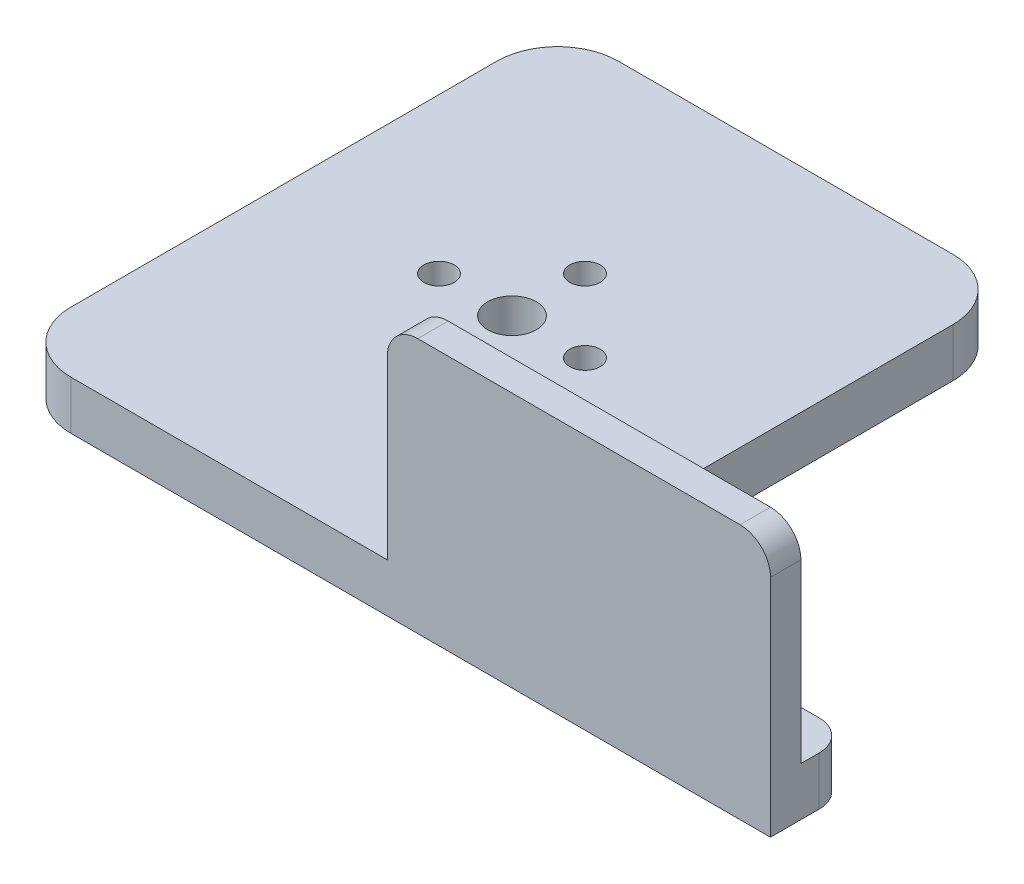
from build123d import *

# Parameters (mm, degrees)
SKETCH1_W           = 75
SKETCH1_H           = 90
SKETCH1_W_2         = 50
SKETCH1_H_2         = 13
BOSS_EXTRUDE1_DEPTH = 8
FILLET2_R           = 10
FILLET3_R           = 10
FILLET4_R           = 10
SKETCH7_W           = 5
SKETCH7_H           = 34
BOSS_EXTRUDE3_DEPTH = 63
FILLET5_R           = 5
FILLET6_R           = 5
FILLET7_R           = 5
SKETCH2_R           = 16
CUT_EXTRUDE1_DEPTH  = 1
CUT_EXTRUDE2_REACH  = 43
SKETCH8_R           = 2.5
SKETCH8_R_2         = 4


with BuildPart() as part:
    # Sketch1 → Boss-Extrude1 (new body)
    with BuildSketch(Plane(origin=(0, 0, 0), x_dir=(1, 0, 0), z_dir=(0, 1, 0))):
        with Locations((37.5, -45)):
            Rectangle(SKETCH1_W, SKETCH1_H)
        with Locations((100, -83.5)):
            Rectangle(SKETCH1_W_2, SKETCH1_H_2)
    extrude(amount=BOSS_EXTRUDE1_DEPTH)

    # Fillet2
    fillet2_edges = [part.edges().sort_by_distance(p)[0] for p in [
        (0, 4, 0),
    ]]
    fillet(fillet2_edges, radius=FILLET2_R)

    # Fillet3
    fillet3_edges = [part.edges().sort_by_distance(p)[0] for p in [
        (0, 4, 90),
    ]]
    fillet(fillet3_edges, radius=FILLET3_R)

    # Fillet4
    fillet4_edges = [part.edges().sort_by_distance(p)[0] for p in [
        (75, 4, 0),
    ]]
    fillet(fillet4_edges, radius=FILLET4_R)

    # Sketch7 → Boss-Extrude3 (add)
    with BuildSketch(Plane(origin=(125, 0, 0), x_dir=(0, 0, -1), z_dir=(1, 0, 0))):
        with Locations((-87.5, 25)):
            Rectangle(SKETCH7_W, SKETCH7_H)
    extrude(amount=-BOSS_EXTRUDE3_DEPTH)

    # Fillet5
    fillet5_edges = [part.edges().sort_by_distance(p)[0] for p in [
        (125, 42, 87.5),
    ]]
    fillet(fillet5_edges, radius=FILLET5_R)

    # Fillet6
    fillet6_edges = [part.edges().sort_by_distance(p)[0] for p in [
        (125, 4, 77),
    ]]
    fillet(fillet6_edges, radius=FILLET6_R)

    # Fillet7
    fillet7_edges = [part.edges().sort_by_distance(p)[0] for p in [
        (62, 42, 87.5),
    ]]
    fillet(fillet7_edges, radius=FILLET7_R)

    # Sketch2 → Cut-Extrude1 (cut)
    with BuildSketch(Plane.XZ):
        with Locations((37.5, 45)):
            Circle(SKETCH2_R)
    extrude(amount=-CUT_EXTRUDE1_DEPTH, mode=Mode.SUBTRACT)

    # Sketch8 → Cut-Extrude2 (cut, up to next)
    with BuildSketch(Plane.XZ.offset(-1), mode=Mode.PRIVATE) as cut_extrude2_sk1:
        with Locations((37.5, 57)):
            Circle(SKETCH8_R)
    cut_extrude2_tool1 = extrude(cut_extrude2_sk1.sketch, amount=-CUT_EXTRUDE2_REACH, mode=Mode.PRIVATE) & part.part
    add(cut_extrude2_tool1.solids().sort_by_distance((37.5, 1, 57))[0], mode=Mode.SUBTRACT)
    # Sketch8 → Cut-Extrude2 (cut, up to next)
    with BuildSketch(Plane.XZ.offset(-1), mode=Mode.PRIVATE) as cut_extrude2_sk2:
        with Locations((37.5, 45)):
            Circle(SKETCH8_R_2)
    cut_extrude2_tool2 = extrude(cut_extrude2_sk2.sketch, amount=-CUT_EXTRUDE2_REACH, mode=Mode.PRIVATE) & part.part
    add(cut_extrude2_tool2.solids().sort_by_distance((37.5, 1, 45))[0], mode=Mode.SUBTRACT)
    # Sketch8 → Cut-Extrude2 (cut, up to next)
    with BuildSketch(Plane.XZ.offset(-1), mode=Mode.PRIVATE) as cut_extrude2_sk3:
        with Locations((49.5, 45)):
            Circle(SKETCH8_R)
    cut_extrude2_tool3 = extrude(cut_extrude2_sk3.sketch, amount=-CUT_EXTRUDE2_REACH, mode=Mode.PRIVATE) & part.part
    add(cut_extrude2_tool3.solids().sort_by_distance((49.5, 1, 45))[0], mode=Mode.SUBTRACT)
    # Sketch8 → Cut-Extrude2 (cut, up to next)
    with BuildSketch(Plane.XZ.offset(-1), mode=Mode.PRIVATE) as cut_extrude2_sk4:
        with Locations((37.5, 33)):
            Circle(SKETCH8_R)
    cut_extrude2_tool4 = extrude(cut_extrude2_sk4.sketch, amount=-CUT_EXTRUDE2_REACH, mode=Mode.PRIVATE) & part.part
    add(cut_extrude2_tool4.solids().sort_by_distance((37.5, 1, 33))[0], mode=Mode.SUBTRACT)
    # Sketch8 → Cut-Extrude2 (cut, up to next)
    with BuildSketch(Plane.XZ.offset(-1), mode=Mode.PRIVATE) as cut_extrude2_sk5:
        with Locations((25.5, 45)):
            Circle(SKETCH8_R)
    cut_extrude2_tool5 = extrude(cut_extrude2_sk5.sketch, amount=-CUT_EXTRUDE2_REACH, mode=Mode.PRIVATE) & part.part
    add(cut_extrude2_tool5.solids().sort_by_distance((25.5, 1, 45))[0], mode=Mode.SUBTRACT)


solid = part.part
